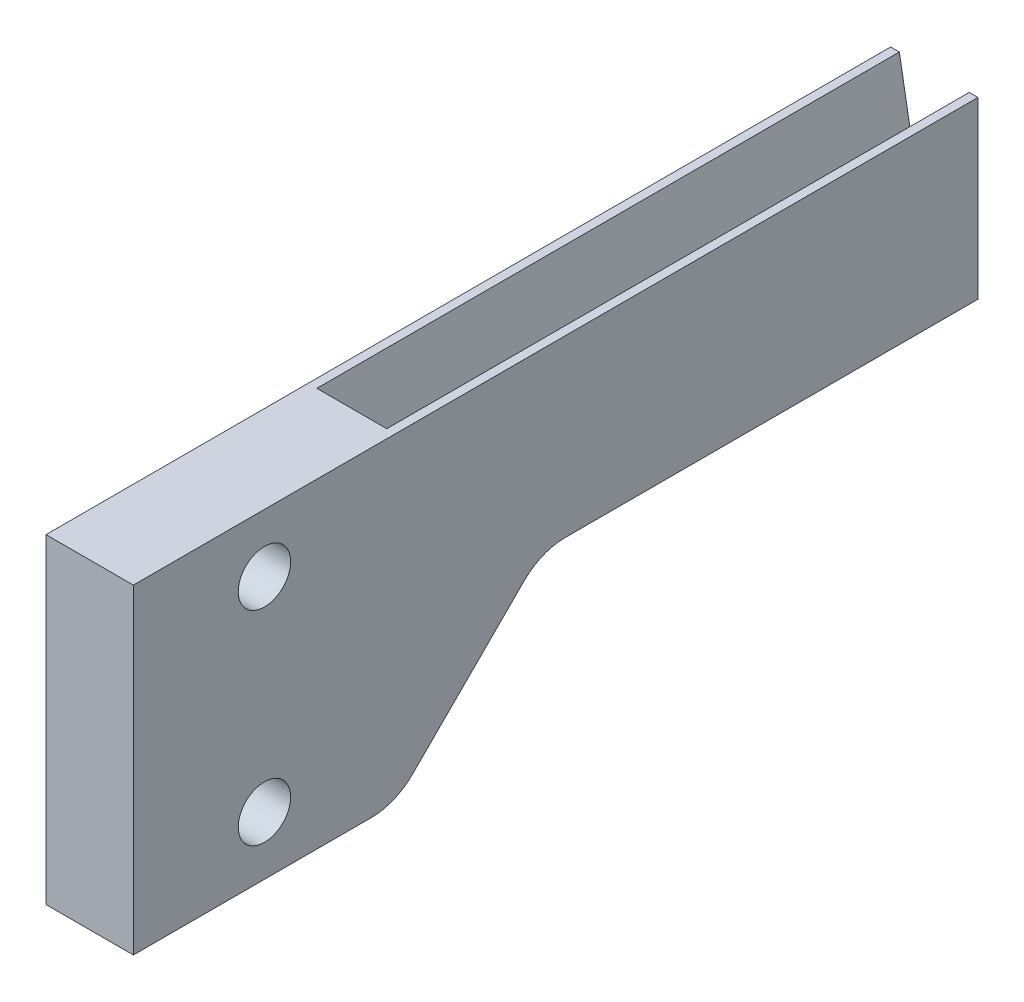
from build123d import *

# Parameters (mm, degrees)
AUFSATZ_LINEAR_AUSTRAGEN1_DEPTH = 100
SKIZZE4_R                       = 4.5
AUFSATZ_LINEAR_AUSTRAGEN2_DEPTH = 15
VERRUNDUNG1_R                   = 10


with BuildPart() as part:
    # Skizze1 → Aufsatz-Linear austragen1 (new body)
    with BuildSketch(Plane.XY):
        Polygon((-5.5, 0), (-5.5, 30), (-4, 30), (0, 7.314872722), (4, 7.314872722), (8, 30), (9.5, 30), (9.5, 0), align=None)
    extrude(amount=AUFSATZ_LINEAR_AUSTRAGEN1_DEPTH)

    # Skizze4 → Aufsatz-Linear austragen2 (add)
    with BuildSketch(Plane.ZY.offset(5.5)):
        with BuildLine():
            Line((100, 30), (145, 30))
            Line((145, 30), (145, -25))
            Line((145, -25), (104.142135624, -25))
            ThreePointArc((104.142135624, -25), (100.3153013, -24.238795325), (97.071067812, -22.071067812))
            Line((97.071067812, -22.071067812), (75, 0))
            Line((75, 0), (100, 0))
            Line((100, 0), (100, 30))
        make_face()
        with Locations((122.5, 20)):
            Circle(SKIZZE4_R, mode=Mode.SUBTRACT)
        with Locations((122.5, -15)):
            Circle(SKIZZE4_R, mode=Mode.SUBTRACT)
    extrude(amount=-AUFSATZ_LINEAR_AUSTRAGEN2_DEPTH)

    # Verrundung1
    verrundung1_edges = [part.edges().sort_by_distance(p)[0] for p in [
        (2, 0, 75),
    ]]
    fillet(verrundung1_edges, radius=VERRUNDUNG1_R)


solid = part.part
